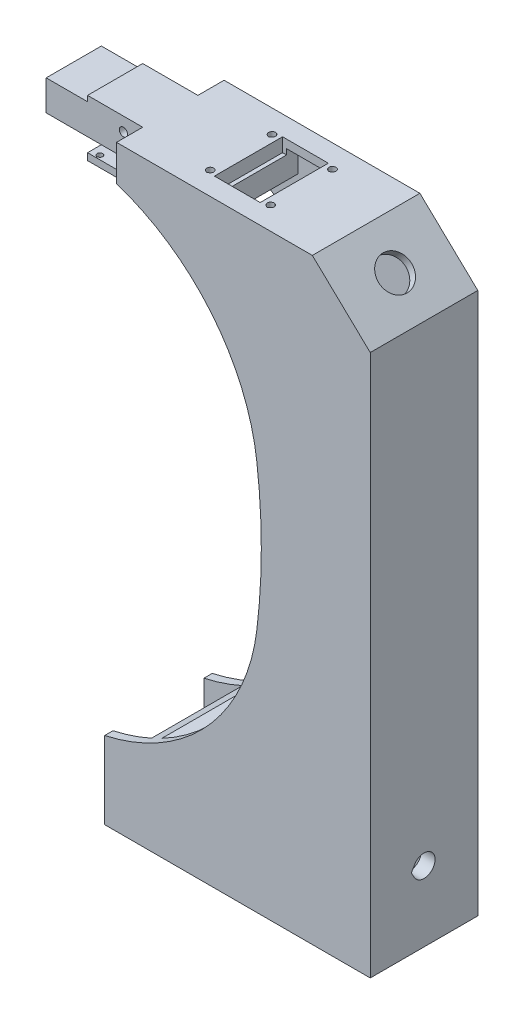
from build123d import *

# Parameters (mm, degrees)
EXTRUDE_6_DEPTH      = 39
CUT_EXTRUDE_START    = 3
CUT_EXTRUDE_2_DEPTH  = 33
EXTRUDE_START        = 9.5
SKETCH_7_W           = 35
SKETCH_7_H           = 13
EXTRUDE_7_DEPTH      = 20
EXTRUDE_START_2      = 4.5
SKETCH_11_W          = 17
SKETCH_11_H          = 2.5
EXTRUDE_15_DEPTH     = 30
CUT_EXTRUDE_START_2  = 180
CUT_EXTRUDE_3_DEPTH  = 10
SKETCH_13_R          = 1.5
CUT_EXTRUDE_4_DEPTH  = 30
SKETCH_14_W          = 15
SKETCH_14_H          = 2
CUT_EXTRUDE_5_DEPTH  = 30
CUT_EXTRUDE_START_3  = 17
CUT_EXTRUDE_7_DEPTH  = 85
CUT_EXTRUDE_START_4  = 13
CUT_EXTRUDE_9_DEPTH  = 5
SKETCH_20_W          = 16.6
SKETCH_20_H          = 24.7
CUT_EXTRUDE_10_DEPTH = 5
SKETCH_21_R          = 6
CUT_EXTRUDE_11_DEPTH = 5


with BuildPart() as part:
    # Эскиз1 → Бобышка-Вытянуть6 (new body)
    with BuildSketch(Plane.XY):
        with BuildLine():
            Line((4.299618531, 175.402841826), (4.299618531, 188.402841826))
            Line((4.299618531, 188.402841826), (75.299618531, 188.402841826))
            Line((75.299618531, 188.402841826), (96.299618531, 168.402841826))
            Line((96.299618531, 168.402841826), (96.299619, 0))
            Line((96.299619, 0), (96.299619, -28))
            Line((96.299619, -28), (0, -28))
            Line((0, -28), (0, 0))
            ThreePointArc((0, 0), (37.229295141, 21.561020186), (55.173142182, 60.662380285))
            ThreePointArc((55.173142182, 60.662380285), (56.797307883, 87.162380285), (55.173142182, 113.662380285))
            ThreePointArc((55.173142182, 113.662380285), (38.726552267, 151.940422917), (4.299618531, 175.402841826))
        make_face()
    extrude(amount=EXTRUDE_6_DEPTH)

    # Эскиз5 → Вырез-Вытянуть2 (cut)
    with BuildSketch(Plane.XY.offset(CUT_EXTRUDE_START)):
        Polygon((34.099618531, 175.402841826), (4.299618531, 175.402841826), (4.299618531, 169.021888999), (-18.700381469, 169.021888999), (-18.700381469, -25), (14, -25), (14, 6.5), (30.299619, 6.5), (30.299619, -25), (91.299619, -25), (91.299619, 169.021888999), (74.099618531, 185.402841826), (34.099618531, 185.402841826), align=None)
    extrude(amount=CUT_EXTRUDE_2_DEPTH, mode=Mode.SUBTRACT)

    # Эскиз7 → Бобышка-Вытянуть7 (add)
    with BuildSketch(Plane.XY.offset(EXTRUDE_START)):
        with Locations((-13.200381469, 181.902841826)):
            Rectangle(SKETCH_7_W, SKETCH_7_H)
    extrude(amount=EXTRUDE_7_DEPTH)

    # Эскиз11 → Бобышка-Вытянуть15 (add)
    with BuildSketch(Plane.XY.offset(EXTRUDE_START_2)):
        with Locations((-2.200381469, 174.152841826)):
            Rectangle(SKETCH_11_W, SKETCH_11_H)
    extrude(amount=EXTRUDE_15_DEPTH)

    # Эскиз12 → Вырез-Вытянуть3 (cut)
    with BuildSketch(Plane(origin=(0, 0, 0), x_dir=(1, 0, 0), z_dir=(0, 1, 0)).offset(CUT_EXTRUDE_START_2)):
        with BuildLine():
            Line((-7.700381469, -34.154700538), (-7.200381469, -33.866025404))
            ThreePointArc((-7.200381469, -33.866025404), (-7.700381469, -32), (-8.200381469, -33.866025404))
            Line((-8.200381469, -33.866025404), (-7.700381469, -34.154700538))
        make_face()
        with BuildLine():
            Line((-7.700381469, -7.154700538), (-7.200381469, -6.866025404))
            ThreePointArc((-7.200381469, -6.866025404), (-7.700381469, -5), (-8.200381469, -6.866025404))
            Line((-8.200381469, -6.866025404), (-7.700381469, -7.154700538))
        make_face()
    extrude(amount=-CUT_EXTRUDE_3_DEPTH, mode=Mode.SUBTRACT)

    # Эскиз13 → Вырез-Вытянуть4 (cut)
    with BuildSketch(Plane.XY):
        with Locations((-2.700381469, 183.402841826)):
            Circle(SKETCH_13_R)
    extrude(amount=CUT_EXTRUDE_4_DEPTH, mode=Mode.SUBTRACT)

    # Эскиз14 → Вырез-Вытянуть5 (cut)
    with BuildSketch(Plane.XY):
        with Locations((-23.200381469, 187.402841826)):
            Rectangle(SKETCH_14_W, SKETCH_14_H)
    extrude(amount=CUT_EXTRUDE_5_DEPTH, mode=Mode.SUBTRACT)

    # Эскиз17 → Вырез-Вытянуть7 (cut)
    with BuildSketch(Plane(origin=(0, 0, 0), x_dir=(0, 0, -1), z_dir=(1, 0, 0)).offset(CUT_EXTRUDE_START_3)):
        with BuildLine():
            Line((-24.118802154, -2.5), (-22.964101615, -0.5))
            ThreePointArc((-22.964101615, -0.5), (-15.5, -2.5), (-22.964101615, -4.5))
            Line((-22.964101615, -4.5), (-24.118802154, -2.5))
        make_face()
    extrude(amount=CUT_EXTRUDE_7_DEPTH, mode=Mode.SUBTRACT)

    # Эскиз18 → Вырез-Вытянуть9 (cut)
    with BuildSketch(Plane(origin=(0, 0, 0), x_dir=(0, 0, -1), z_dir=(1, 0, 0)).offset(CUT_EXTRUDE_START_4)):
        with BuildLine():
            Line((-21.809401077, -2.5), (-21.232050808, -1.5))
            ThreePointArc((-21.232050808, -1.5), (-17.5, -2.5), (-21.232050808, -3.5))
            Line((-21.232050808, -3.5), (-21.809401077, -2.5))
        make_face()
    extrude(amount=CUT_EXTRUDE_9_DEPTH, mode=Mode.SUBTRACT)

    # Эскиз20 → Вырез-Вытянуть10 (cut)
    with BuildSketch(Plane(origin=(0, 188.402841826, 0), x_dir=(1, 0, 0), z_dir=(0, 1, 0))):
        with Locations((40.95, -19.5)):
            Rectangle(SKETCH_20_W, SKETCH_20_H)
        with BuildLine():
            Line((30, -32.143375673), (30.625, -31.782531755))
            ThreePointArc((30.625, -31.782531755), (30, -29.45), (29.375, -31.782531755))
            Line((29.375, -31.782531755), (30, -32.143375673))
        make_face()
        with BuildLine():
            Line((30, -9.743375673), (30.625, -9.382531755))
            ThreePointArc((30.625, -9.382531755), (30, -7.05), (29.375, -9.382531755))
            Line((29.375, -9.382531755), (30, -9.743375673))
        make_face()
        with BuildLine():
            Line((51.9, -9.743375673), (52.525, -9.382531755))
            ThreePointArc((52.525, -9.382531755), (51.9, -7.05), (51.275, -9.382531755))
            Line((51.275, -9.382531755), (51.9, -9.743375673))
        make_face()
        with BuildLine():
            Line((51.9, -32.143375673), (52.525, -31.782531755))
            ThreePointArc((52.525, -31.782531755), (51.9, -29.45), (51.275, -31.782531755))
            Line((51.275, -31.782531755), (51.9, -32.143375673))
        make_face()
    extrude(amount=-CUT_EXTRUDE_10_DEPTH, mode=Mode.SUBTRACT)

    # Эскиз21 → Вырез-Вытянуть11 (cut)
    with BuildSketch(Plane(origin=(129.903734815, 136.398921556, 0), x_dir=(0, 0, -1), z_dir=(0.689655172, 0.724137931, 0))):
        with Locations((-19.5, 60.905684392)):
            Circle(SKETCH_21_R)
    extrude(amount=-CUT_EXTRUDE_11_DEPTH, mode=Mode.SUBTRACT)


solid = part.part
